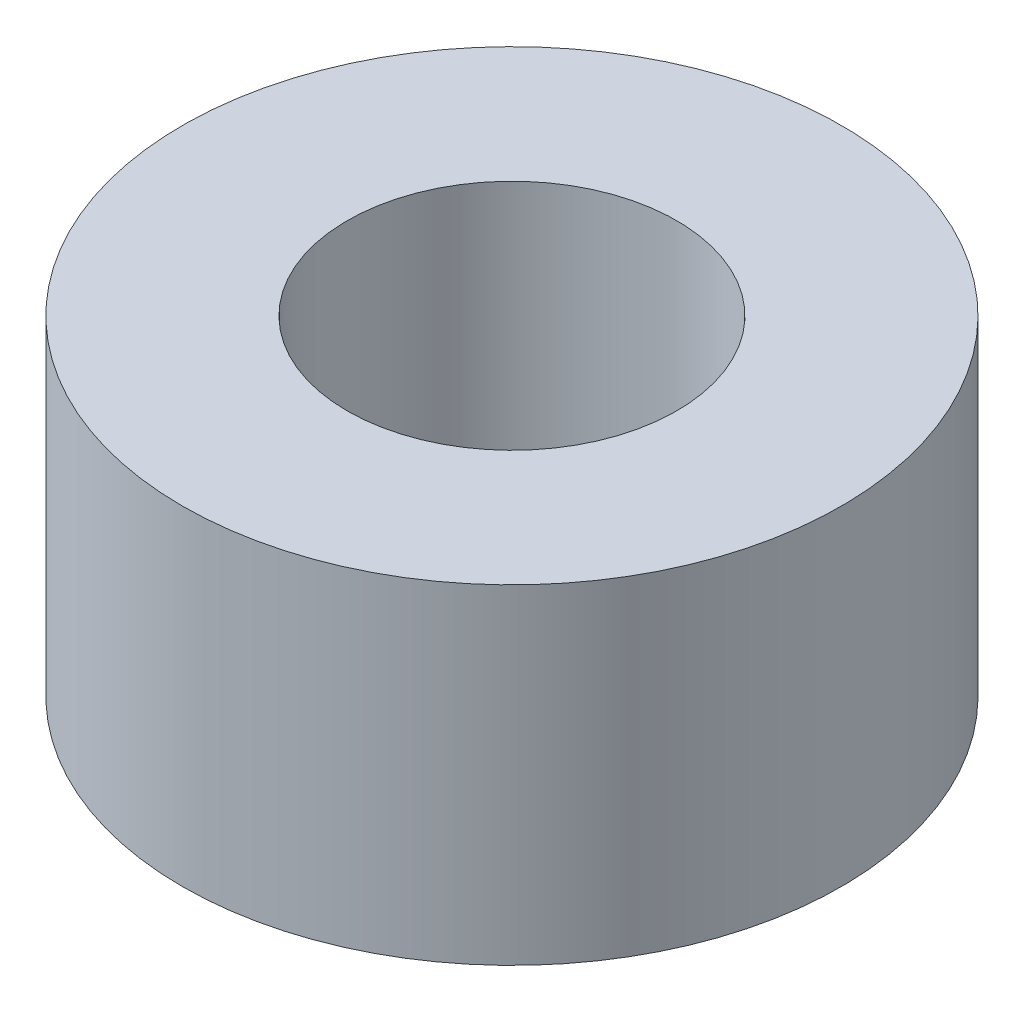
from build123d import *

# Parameters (mm, degrees)
SKETCH1_R           = 3
SKETCH1_R_2         = 1.5
BOSS_EXTRUDE1_DEPTH = 3


with BuildPart() as part:
    # Sketch1 → Boss-Extrude1 (new body)
    with BuildSketch(Plane(origin=(0, 0, 0), x_dir=(1, 0, 0), z_dir=(0, 1, 0))):
        Circle(SKETCH1_R)
        Circle(SKETCH1_R_2, mode=Mode.SUBTRACT)
    extrude(amount=BOSS_EXTRUDE1_DEPTH)


solid = part.part
